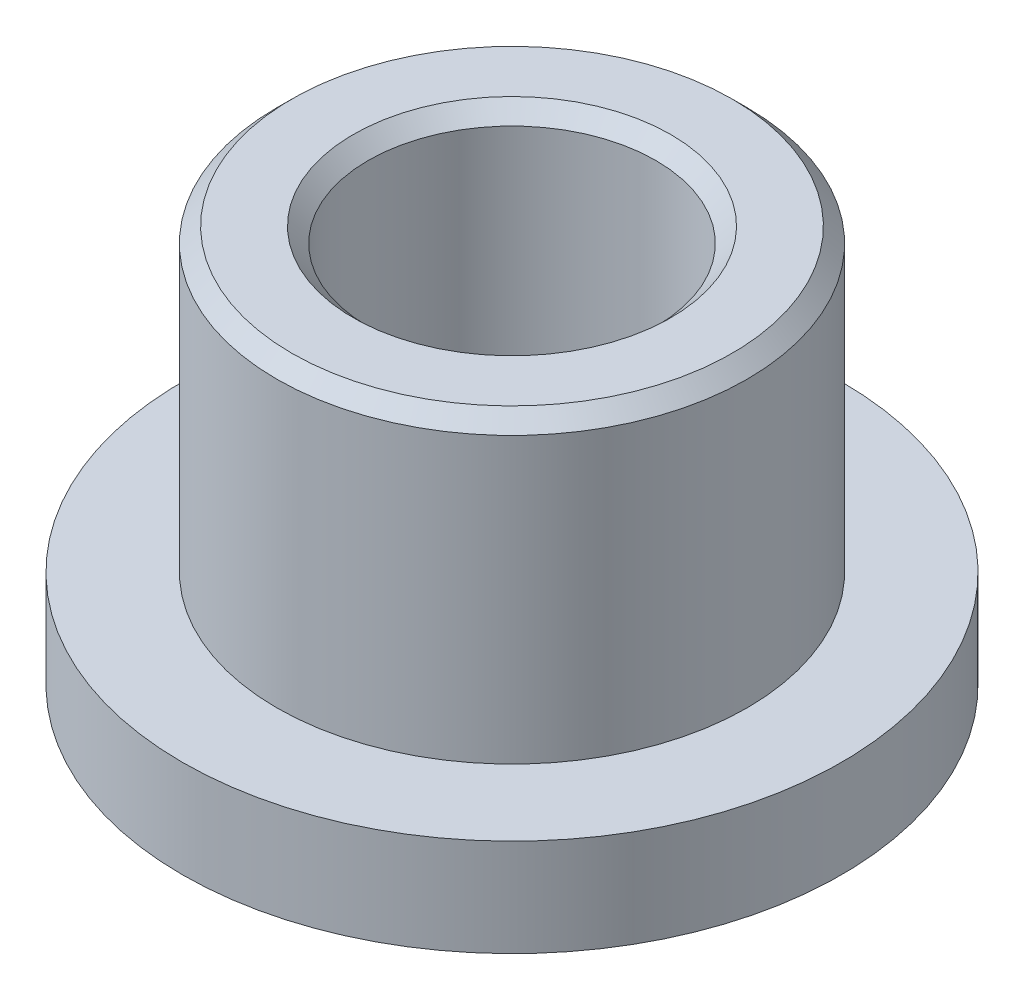
from build123d import *

# Parameters (mm, degrees)
CUT_EXTRUDE1_DEPTH      = 15.637622758
CUT_EXTRUDE1_DEPTH_BACK = 15.637622758
SKETCH2_W               = 14
SKETCH2_H               = 8
CHAMFER1_SIZE           = 0.25


with BuildPart() as part:
    # Sketch1 → Revolve1 (revolve)
    with BuildSketch(Plane.XY):
        Polygon((3.925, 1.6256), (3.925, 12.4), (2.4, 12.4), (2.4, 0.2), (2.6, 0), (5.5, 0), (5.5, 1.6256), align=None)
    revolve(axis=Axis((0, 0, 0), (0, -1, 0)))

    # Sketch2 → Cut-Extrude1 (cut, two sides: drawn at the far end of the back side and taken through both)
    with BuildSketch(Plane.XY.offset(-CUT_EXTRUDE1_DEPTH_BACK)):
        with Locations((0, 10.6256)):
            Rectangle(SKETCH2_W, SKETCH2_H)
    extrude(amount=CUT_EXTRUDE1_DEPTH + CUT_EXTRUDE1_DEPTH_BACK, mode=Mode.SUBTRACT)

    # Chamfer1
    chamfer1_edges = [part.edges().sort_by_distance(p)[0] for p in [
        (-2.4, 6.6256, 0),
        (-3.925, 6.6256, 0),
    ]]
    chamfer(chamfer1_edges, length=CHAMFER1_SIZE)


solid = part.part
